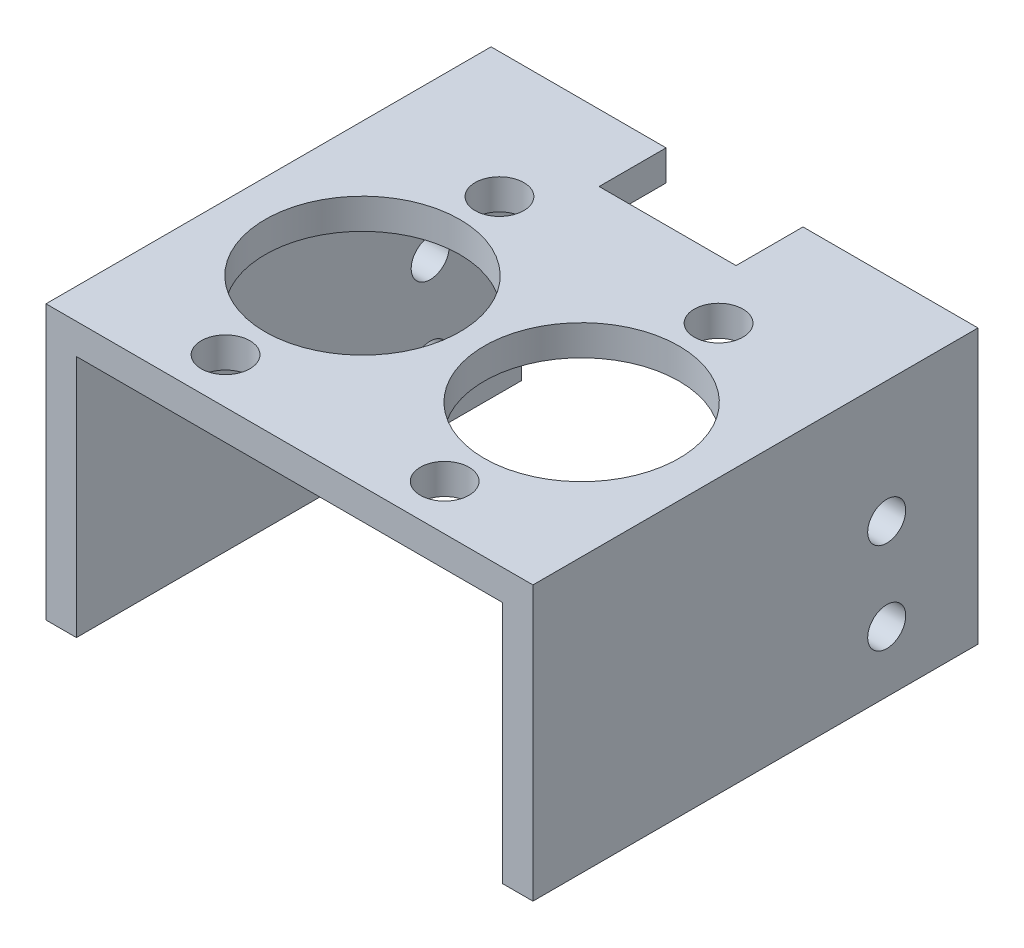
from build123d import *

# Parameters (mm, degrees)
SKETCH1_W                   = 6.35
SKETCH1_H                   = 57.15
SKETCH1_W_2                 = 88.9
SKETCH1_H_2                 = 6.35
BOSS_EXTRUDE1_DEPTH         = 92.86494
MASTER_CYLINDER_MOUNT_REACH = 59.15
SKETCH2_R                   = 5.08
SKETCH2_R_2                 = 20.32
SKETCH3_R                   = 3.96875
BRACKET_MOUNT_DEPTH         = 102.6


with BuildPart() as part:
    # Sketch1 → Boss-Extrude1 (new body)
    with BuildSketch(Plane.XY):
        with Locations((-109.443697604, 28.678448761)):
            Rectangle(SKETCH1_W, SKETCH1_H)
        with Locations((-61.818697604, 54.078448761)):
            Rectangle(SKETCH1_W_2, SKETCH1_H_2)
        Polygon((-17.368697604, 57.253448761), (-17.368697604, 50.903448761), (-17.368697604, 0.103448761), (-11.018697604, 0.103448761), (-11.018697604, 57.253448761), align=None)
    extrude(amount=BOSS_EXTRUDE1_DEPTH)

    # Sketch2 → Master Cylinder Mount (cut, up to next)
    with BuildSketch(Plane(origin=(0, 57.253448761, 0), x_dir=(1, 0, 0), z_dir=(0, 1, 0)), mode=Mode.PRIVATE) as master_cylinder_mount_sk1:
        Polygon((-47.531197604, 0), (-76.106197604, 0), (-76.106197604, -13.97), (-69.121197604, -13.97), (-54.516197604, -13.97), (-47.531197604, -13.97), align=None)
    master_cylinder_mount_tool1 = extrude(master_cylinder_mount_sk1.sketch, amount=-MASTER_CYLINDER_MOUNT_REACH, mode=Mode.PRIVATE) & part.part
    add(master_cylinder_mount_tool1.solids().sort_by_distance((-61.818698, 57.253449, 6.985))[0], mode=Mode.SUBTRACT)
    # Sketch2 → Master Cylinder Mount (cut, up to next)
    with BuildSketch(Plane(origin=(0, 57.253448761, 0), x_dir=(1, 0, 0), z_dir=(0, 1, 0)), mode=Mode.PRIVATE) as master_cylinder_mount_sk2:
        with Locations((-38.958697604, -26.18994)):
            Circle(SKETCH2_R)
    master_cylinder_mount_tool2 = extrude(master_cylinder_mount_sk2.sketch, amount=-MASTER_CYLINDER_MOUNT_REACH, mode=Mode.PRIVATE) & part.part
    add(master_cylinder_mount_tool2.solids().sort_by_distance((-38.958698, 57.253449, 26.18994))[0], mode=Mode.SUBTRACT)
    # Sketch2 → Master Cylinder Mount (cut, up to next)
    with BuildSketch(Plane(origin=(0, 57.253448761, 0), x_dir=(1, 0, 0), z_dir=(0, 1, 0)), mode=Mode.PRIVATE) as master_cylinder_mount_sk3:
        with Locations((-84.678697604, -26.18994)):
            Circle(SKETCH2_R)
    master_cylinder_mount_tool3 = extrude(master_cylinder_mount_sk3.sketch, amount=-MASTER_CYLINDER_MOUNT_REACH, mode=Mode.PRIVATE) & part.part
    add(master_cylinder_mount_tool3.solids().sort_by_distance((-84.678698, 57.253449, 26.18994))[0], mode=Mode.SUBTRACT)
    # Sketch2 → Master Cylinder Mount (cut, up to next)
    with BuildSketch(Plane(origin=(0, 57.253448761, 0), x_dir=(1, 0, 0), z_dir=(0, 1, 0)), mode=Mode.PRIVATE) as master_cylinder_mount_sk4:
        with Locations((-84.678697604, -83.33994)):
            Circle(SKETCH2_R)
    master_cylinder_mount_tool4 = extrude(master_cylinder_mount_sk4.sketch, amount=-MASTER_CYLINDER_MOUNT_REACH, mode=Mode.PRIVATE) & part.part
    add(master_cylinder_mount_tool4.solids().sort_by_distance((-84.678698, 57.253449, 83.33994))[0], mode=Mode.SUBTRACT)
    # Sketch2 → Master Cylinder Mount (cut, up to next)
    with BuildSketch(Plane(origin=(0, 57.253448761, 0), x_dir=(1, 0, 0), z_dir=(0, 1, 0)), mode=Mode.PRIVATE) as master_cylinder_mount_sk5:
        with Locations((-38.958697604, -83.33994)):
            Circle(SKETCH2_R)
    master_cylinder_mount_tool5 = extrude(master_cylinder_mount_sk5.sketch, amount=-MASTER_CYLINDER_MOUNT_REACH, mode=Mode.PRIVATE) & part.part
    add(master_cylinder_mount_tool5.solids().sort_by_distance((-38.958698, 57.253449, 83.33994))[0], mode=Mode.SUBTRACT)
    # Sketch2 → Master Cylinder Mount (cut, up to next)
    with BuildSketch(Plane(origin=(0, 57.253448761, 0), x_dir=(1, 0, 0), z_dir=(0, 1, 0)), mode=Mode.PRIVATE) as master_cylinder_mount_sk6:
        with Locations((-38.958697604, -54.76494)):
            Circle(SKETCH2_R_2)
    master_cylinder_mount_tool6 = extrude(master_cylinder_mount_sk6.sketch, amount=-MASTER_CYLINDER_MOUNT_REACH, mode=Mode.PRIVATE) & part.part
    add(master_cylinder_mount_tool6.solids().sort_by_distance((-38.958698, 57.253449, 54.76494))[0], mode=Mode.SUBTRACT)
    # Sketch2 → Master Cylinder Mount (cut, up to next)
    with BuildSketch(Plane(origin=(0, 57.253448761, 0), x_dir=(1, 0, 0), z_dir=(0, 1, 0)), mode=Mode.PRIVATE) as master_cylinder_mount_sk7:
        with Locations((-84.678697604, -54.76494)):
            Circle(SKETCH2_R_2)
    master_cylinder_mount_tool7 = extrude(master_cylinder_mount_sk7.sketch, amount=-MASTER_CYLINDER_MOUNT_REACH, mode=Mode.PRIVATE) & part.part
    add(master_cylinder_mount_tool7.solids().sort_by_distance((-84.678698, 57.253449, 54.76494))[0], mode=Mode.SUBTRACT)

    # Sketch3 → Bracket Mount (cut, through all)
    with BuildSketch(Plane.ZY.offset(112.618697604)):
        with Locations((19.05, 12.803448761)):
            Circle(SKETCH3_R)
        with Locations((19.05, 31.853448761)):
            Circle(SKETCH3_R)
    extrude(amount=-BRACKET_MOUNT_DEPTH, mode=Mode.SUBTRACT)


solid = part.part
